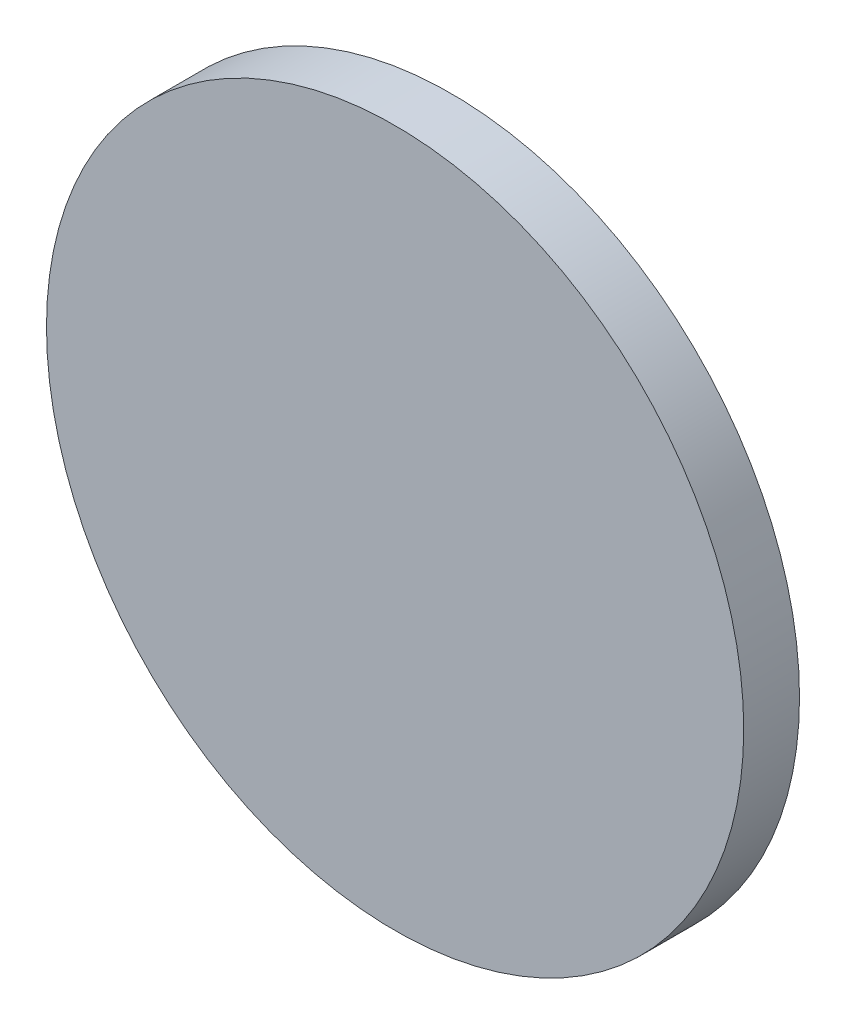
from build123d import *

# Parameters (mm, degrees)
SKETCH_1_R      = 25
EXTRUDE_1_DEPTH = 4


with BuildPart() as part:
    # 草图1 → 凸台-拉伸1 (new body)
    with BuildSketch(Plane.XY):
        Circle(SKETCH_1_R)
    extrude(amount=EXTRUDE_1_DEPTH)


solid = part.part
